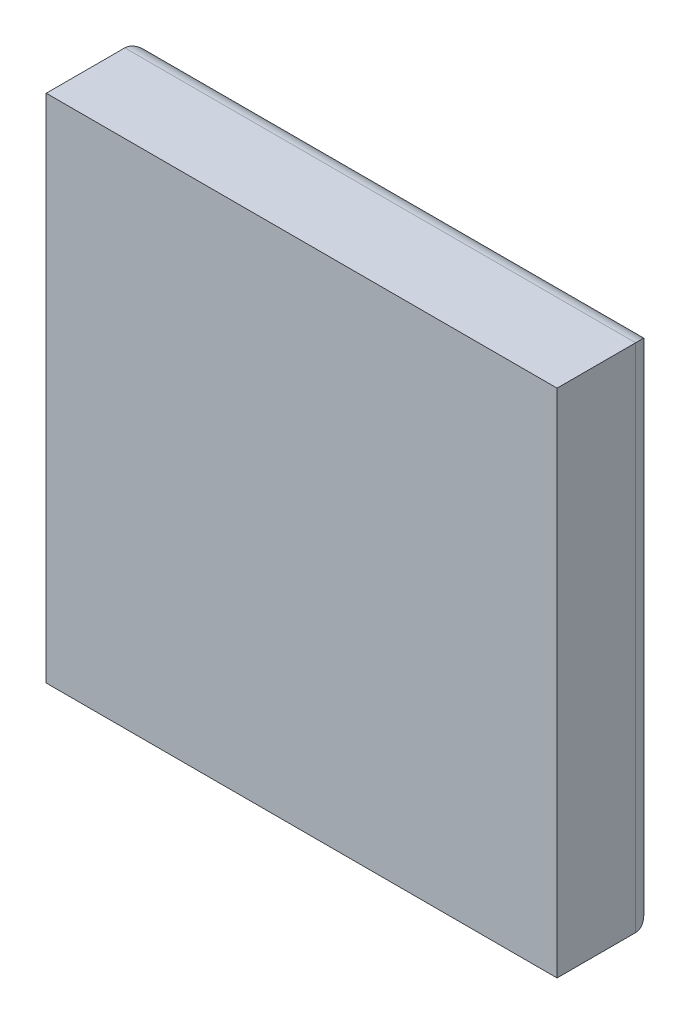
from build123d import *

# Parameters (mm, degrees)
ESBO_O1_W                = 26
ESBO_O1_H                = 26
RESSALTO_EXTRUS_O1_DEPTH = 5
FILETE1_R                = 1


with BuildPart() as part:
    # Esboço1 → Ressalto-extrusão1 (new body)
    with BuildSketch(Plane.XY):
        with Locations((-23.839817203, -14.136932447)):
            Rectangle(ESBO_O1_W, ESBO_O1_H)
    extrude(amount=RESSALTO_EXTRUS_O1_DEPTH)

    # Filete1
    filete1_edges = [part.edges().sort_by_distance(p)[0] for p in [
        (-23.839817203, -1.136932447, 0),
        (-10.839817203, -14.136932447, 0),
        (-23.839817203, -27.136932447, 0),
        (-36.839817203, -14.136932447, 0),
    ]]
    fillet(filete1_edges, radius=FILETE1_R)


solid = part.part
